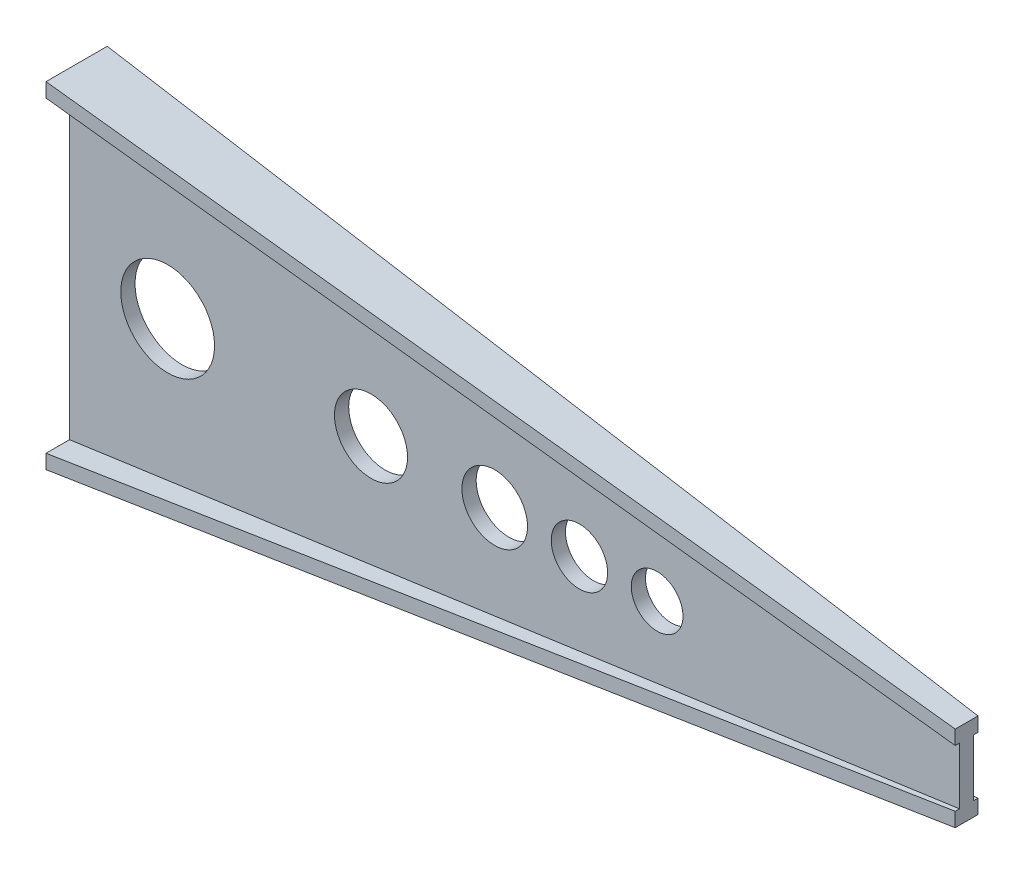
from build123d import *

# Parameters (mm, degrees)
SKETCH5_R          = 65.838775907
SKETCH5_R_2        = 51.340137945
SKETCH5_R_3        = 46.082776278
SKETCH5_R_4        = 36.313221665
SKETCH5_R_5        = 39.620905692
CUT_EXTRUDE1_DEPTH = 54.0000001


with BuildPart() as part:
    # Sketch1 → Loft l4 section 0
    with BuildSketch(Plane(origin=(0, 0, 0), x_dir=(0, 0, -1), z_dir=(1, 0, 0))):
        Polygon((-53, 236), (33, 236), (33, 216), (0, 216), (0, -216), (33, -216), (33, -236), (-53, -236), (-53, -216), (-20, -216), (-20, 216), (-53, 216), align=None)
    # Sketch4 → Loft l4 section 1
    with BuildSketch(Plane(origin=(1250, 0, -1000), x_dir=(0, 0, 1), z_dir=(-1, 0, 0))):
        Polygon((994, 60), (1026, 60), (1026, 40), (1020, 40), (1020, -40), (1026, -40), (1026, -60), (994, -60), (994, -40), (1000, -40), (1000, 40), (994, 40), align=None)
    loft()

    # Sketch5 → Cut-Extrude1 (cut, through all)
    with BuildSketch(Plane.XY.offset(20)):
        with Locations((137.875176339, 0)):
            Circle(SKETCH5_R)
        with Locations((423.461863642, 0)):
            Circle(SKETCH5_R_2)
        with Locations((597.226106195, 0)):
            Circle(SKETCH5_R_3)
        with Locations((825.313339697, 0)):
            Circle(SKETCH5_R_4)
        with Locations((716.202882206, 0)):
            Circle(SKETCH5_R_5)
    extrude(amount=-CUT_EXTRUDE1_DEPTH, mode=Mode.SUBTRACT)


solid = part.part
